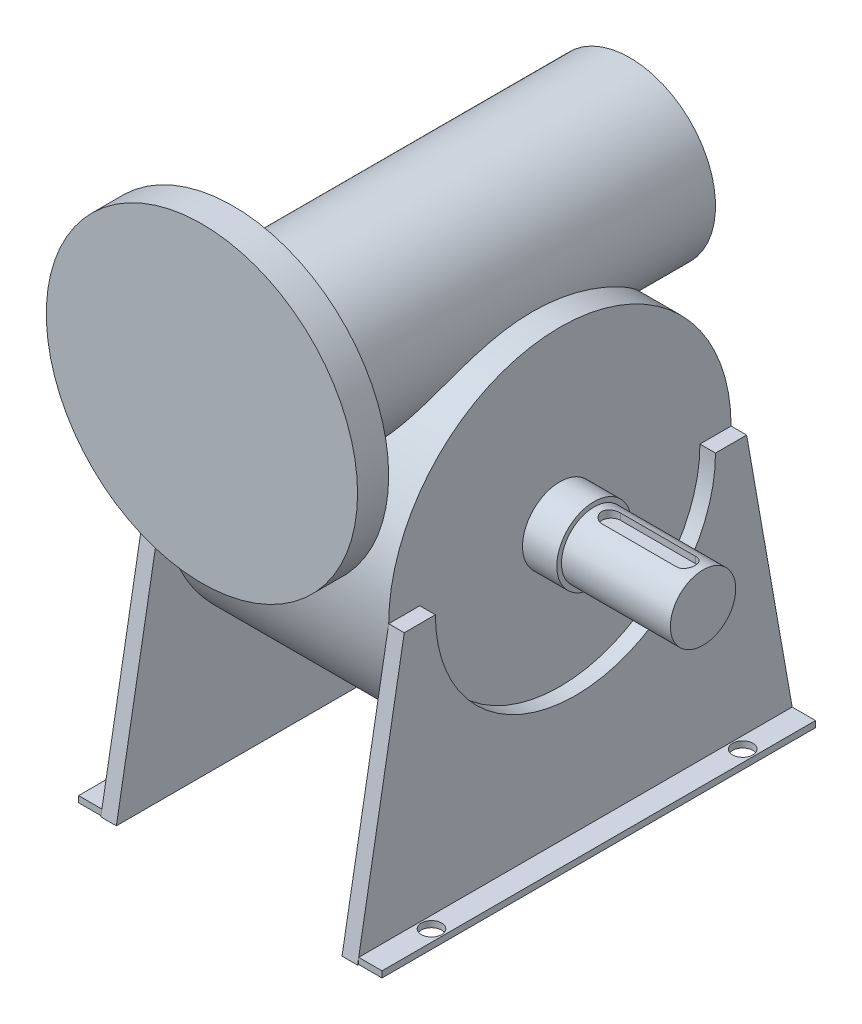
from build123d import *

# Parameters (mm, degrees)
SKETCH1_R                  = 100
BOSS_EXTRUDE1_DEPTH        = 20
SKETCH2_R                  = 55
BOSS_EXTRUDE2_DEPTH        = 255
SKETCH3_R                  = 110
BOSS_EXTRUDE3_DEPTH        = 72.5
BOSS_EXTRUDE4_DEPTH        = 10
MIRROR4_COPY_1_DEPTH       = 10
MIRROR4_COPY_2_DEPTH       = 10
SKETCH5_R                  = 21
BOSS_EXTRUDE5_DEPTH        = 92
SKETCH7_R                  = 24
BOSS_EXTRUDE6_DEPTH        = 22
CUT_EXTRUDE1_DEPTH         = 5
SKETCH8_W                  = 278.540557596
SKETCH8_H                  = 4
BOSS_EXTRUDE7_DEPTH        = 15
F_13_0_13_DIAMETER_HOLE1_D = 13


with BuildPart() as part:
    # Sketch1 → Boss-Extrude1 (new body)
    with BuildSketch(Plane.XY):
        Circle(SKETCH1_R)
    extrude(amount=BOSS_EXTRUDE1_DEPTH)

    # Sketch2 → Boss-Extrude2 (add)
    with BuildSketch(Plane(origin=(0, 0, 0), x_dir=(-1, 0, 0), z_dir=(0, 0, -1))):
        Circle(SKETCH2_R)
    extrude(amount=BOSS_EXTRUDE2_DEPTH)

    # Sketch3 → Boss-Extrude3 (add, symmetric)
    with BuildSketch(Plane(origin=(0, 0, 0), x_dir=(0, 0, -1), z_dir=(1, 0, 0))):
        with Locations((137.5, -110)):
            Circle(SKETCH3_R)
    extrude(amount=BOSS_EXTRUDE3_DEPTH, both=True)

    # Sketch4 → Boss-Extrude4 (add)
    with BuildSketch(Plane(origin=(72.5, 0, 0), x_dir=(0, 0, -1), z_dir=(1, 0, 0))):
        with BuildLine():
            Line((-2.47558672, -280), (137.5, -280))
            Line((137.5, -280), (137.5, -200))
            ThreePointArc((137.5, -200), (73.860389693, -173.639610307), (47.5, -110))
            Line((47.5, -110), (27.5, -110))
            Line((27.5, -110), (-2.47558672, -280))
        make_face()
    boss_extrude4 = extrude(amount=BOSS_EXTRUDE4_DEPTH)

    # Mirror1: Boss-Extrude4 across plane
    add(boss_extrude4.mirror(Plane(origin=(82.5, 0, -137.5), x_dir=(1, 0, 0), z_dir=(0, 0, 1))))

    # Mirror3: Boss-Extrude4 across plane
    add(boss_extrude4.mirror(Plane(origin=(0, 0, 0), x_dir=(0, 0, 1), z_dir=(1, 0, 0))))

    # Mirror4 copy 1 sketch → Mirror4 copy 1 (add)
    with BuildSketch(Plane(origin=(-72.5, 0, -275), x_dir=(0, 0, 1), z_dir=(-1, 0, 0))):
        with BuildLine():
            Line((-2.47558672, -280), (137.5, -280))
            Line((137.5, -280), (137.5, -200))
            ThreePointArc((137.5, -200), (73.860389693, -173.639610307), (47.5, -110))
            Line((47.5, -110), (27.5, -110))
            Line((27.5, -110), (-2.47558672, -280))
        make_face()
    extrude(amount=MIRROR4_COPY_1_DEPTH)

    # Mirror4 copy 2 sketch → Mirror4 copy 2 (add)
    with BuildSketch(Plane(origin=(72.5, 0, -275), x_dir=(0, 0, 1), z_dir=(1, 0, 0))):
        with BuildLine():
            Line((-2.47558672, 280), (137.5, 280))
            Line((137.5, 280), (137.5, 200))
            ThreePointArc((137.5, 200), (73.860389693, 173.639610307), (47.5, 110))
            Line((47.5, 110), (27.5, 110))
            Line((27.5, 110), (-2.47558672, 280))
        make_face()
    extrude(amount=MIRROR4_COPY_2_DEPTH)

    # Sketch5 → Boss-Extrude5 (add)
    with BuildSketch(Plane(origin=(72.5, 0, 0), x_dir=(0, 0, -1), z_dir=(1, 0, 0))):
        with Locations((137.5, -110)):
            Circle(SKETCH5_R)
    extrude(amount=BOSS_EXTRUDE5_DEPTH)

    # Sketch7 → Boss-Extrude6 (add)
    with BuildSketch(Plane(origin=(72.5, 0, 0), x_dir=(0, 0, -1), z_dir=(1, 0, 0))):
        with Locations((137.5, -110)):
            Circle(SKETCH7_R)
    extrude(amount=BOSS_EXTRUDE6_DEPTH)

    # Sketch6 → Cut-Extrude1 (cut)
    with BuildSketch(Plane(origin=(0, -89, 0), x_dir=(1, 0, 0), z_dir=(0, 1, 0))):
        with BuildLine():
            Line((105.5, 143.5), (129.5, 143.5))
            Line((129.5, 143.5), (129.5, 131.5))
            Line((129.5, 131.5), (105.5, 131.5))
            ThreePointArc((105.5, 131.5), (99.5, 137.5), (105.5, 143.5))
        make_face()
    cut_extrude1 = extrude(amount=-CUT_EXTRUDE1_DEPTH, mode=Mode.SUBTRACT)

    # Mirror5: Cut-Extrude1 across plane
    add(cut_extrude1.mirror(Plane(origin=(129.5, -94, -143.5), x_dir=(0, 0, 1), z_dir=(1, 0, 0))), mode=Mode.SUBTRACT)

    # Sketch8 → Boss-Extrude7 (add)
    with BuildSketch(Plane(origin=(82.5, 0, 0), x_dir=(0, 0, -1), z_dir=(1, 0, 0))):
        with Locations((137.5, -278)):
            Rectangle(SKETCH8_W, SKETCH8_H)
    boss_extrude7 = extrude(amount=BOSS_EXTRUDE7_DEPTH)

    # Ø13.0 (13) Diameter Hole1 (through all)
    with Locations(Plane(origin=(0, -280, 0), x_dir=(-1, 0, 0), z_dir=(0, -1, 0))):
        with Locations((-90, 37.5), (-90, 237.5)):
            f_13_0_13_diameter_hole1 = Hole(F_13_0_13_DIAMETER_HOLE1_D / 2)

    # Mirror8: Boss-Extrude7, Ø13.0 (13) Diameter Hole1 across plane
    add(boss_extrude7.mirror(Plane(origin=(0, 0, 0), x_dir=(0, 0, 1), z_dir=(1, 0, 0))))
    add(f_13_0_13_diameter_hole1.mirror(Plane(origin=(0, 0, 0), x_dir=(0, 0, 1), z_dir=(1, 0, 0))), mode=Mode.SUBTRACT)


solid = part.part
